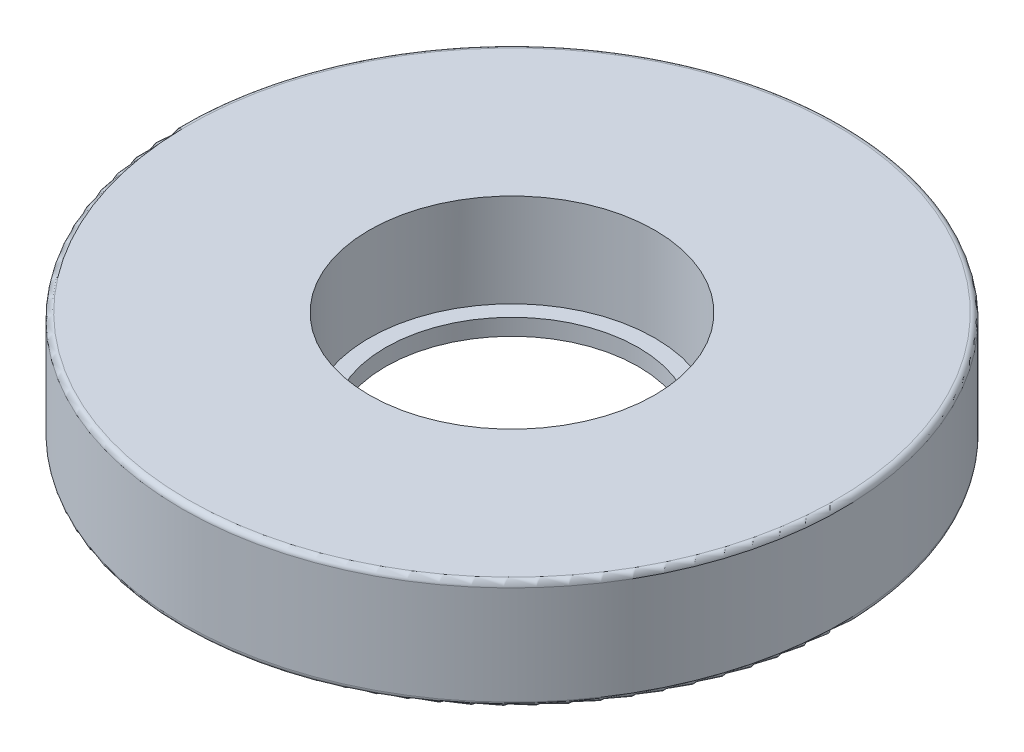
from build123d import *

# Parameters (mm, degrees)
SKETCH_1_R      = 60
SKETCH_1_R_2    = 26
EXTRUDE_1_DEPTH = 20
FILLET_1_R      = 1
SKETCH_2_R      = 26
SKETCH_2_R_2    = 23
EXTRUDE_2_DEPTH = 3


with BuildPart() as part:
    # 草图1 → 凸台-拉伸1 (new body)
    with BuildSketch(Plane(origin=(0, 0, 0), x_dir=(1, 0, 0), z_dir=(0, 1, 0))):
        Circle(SKETCH_1_R)
        Circle(SKETCH_1_R_2, mode=Mode.SUBTRACT)
    extrude(amount=EXTRUDE_1_DEPTH)

    # 圆角1
    fillet_1_edges = [part.edges().sort_by_distance(p)[0] for p in [
        (-60, 0, 0),
        (-60, 20, 0),
    ]]
    fillet(fillet_1_edges, radius=FILLET_1_R)

    # 草图2 → 凸台-拉伸2 (add)
    with BuildSketch(Plane.XZ):
        Circle(SKETCH_2_R)
        Circle(SKETCH_2_R_2, mode=Mode.SUBTRACT)
    extrude(amount=-EXTRUDE_2_DEPTH)


solid = part.part
